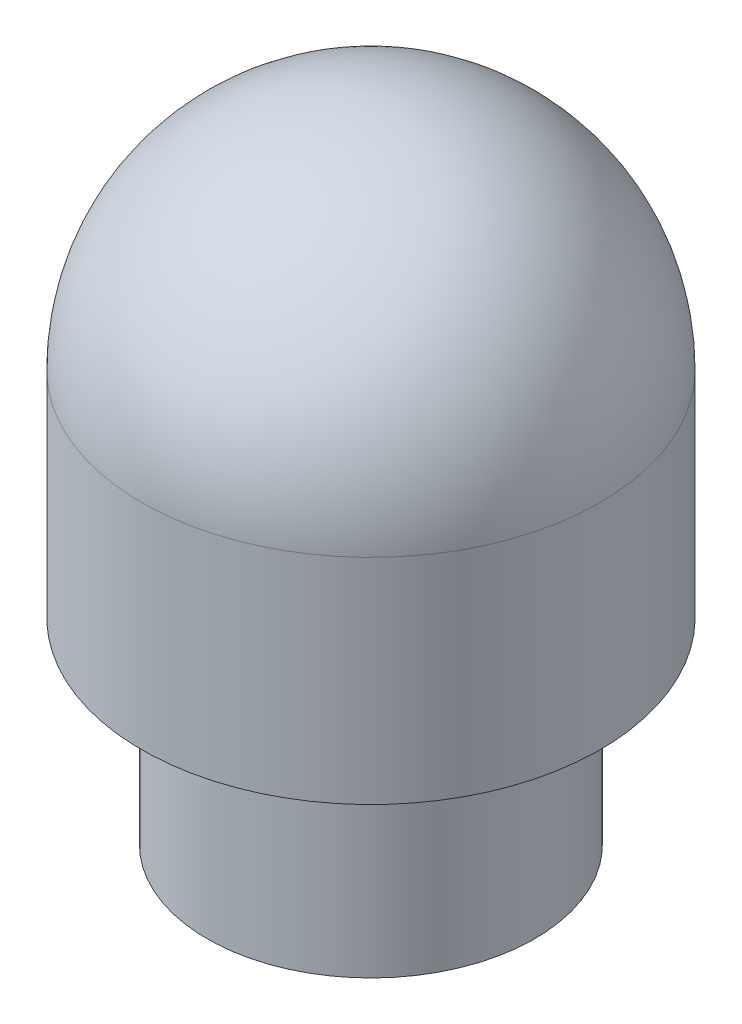
from build123d import *

# Parameters (mm, degrees)
SKETCH3_R          = 3
CUT_EXTRUDE1_DEPTH = 13.97
FILLET1_R          = 3


with BuildPart() as part:
    # Sketch2 → Revolve1 (revolve)
    with BuildSketch(Plane(origin=(0, 0, 0), x_dir=(0, 0, -1), z_dir=(1, 0, 0))):
        with BuildLine():
            Line((0, 0), (0, 15.5067))
            ThreePointArc((0, 15.5067), (3.928862053, 13.879312053), (5.55625, 9.95045))
            Line((5.55625, 9.95045), (5.55625, 4.7625))
            Line((5.55625, 4.7625), (3.96875, 4.7625))
            Line((3.96875, 4.7625), (3.96875, 0))
            Line((3.96875, 0), (0, 0))
        make_face()
    revolve(axis=Axis((0, 0, 0), (0, 1, 0)))

    # Sketch3 → Cut-Extrude1 (cut)
    with BuildSketch(Plane.XZ):
        Circle(SKETCH3_R)
    extrude(amount=-CUT_EXTRUDE1_DEPTH, mode=Mode.SUBTRACT)

    # Fillet1
    fillet1_edges = [part.edges().sort_by_distance(p)[0] for p in [
        (-3, 13.97, 0),
    ]]
    fillet(fillet1_edges, radius=FILLET1_R)


solid = part.part
